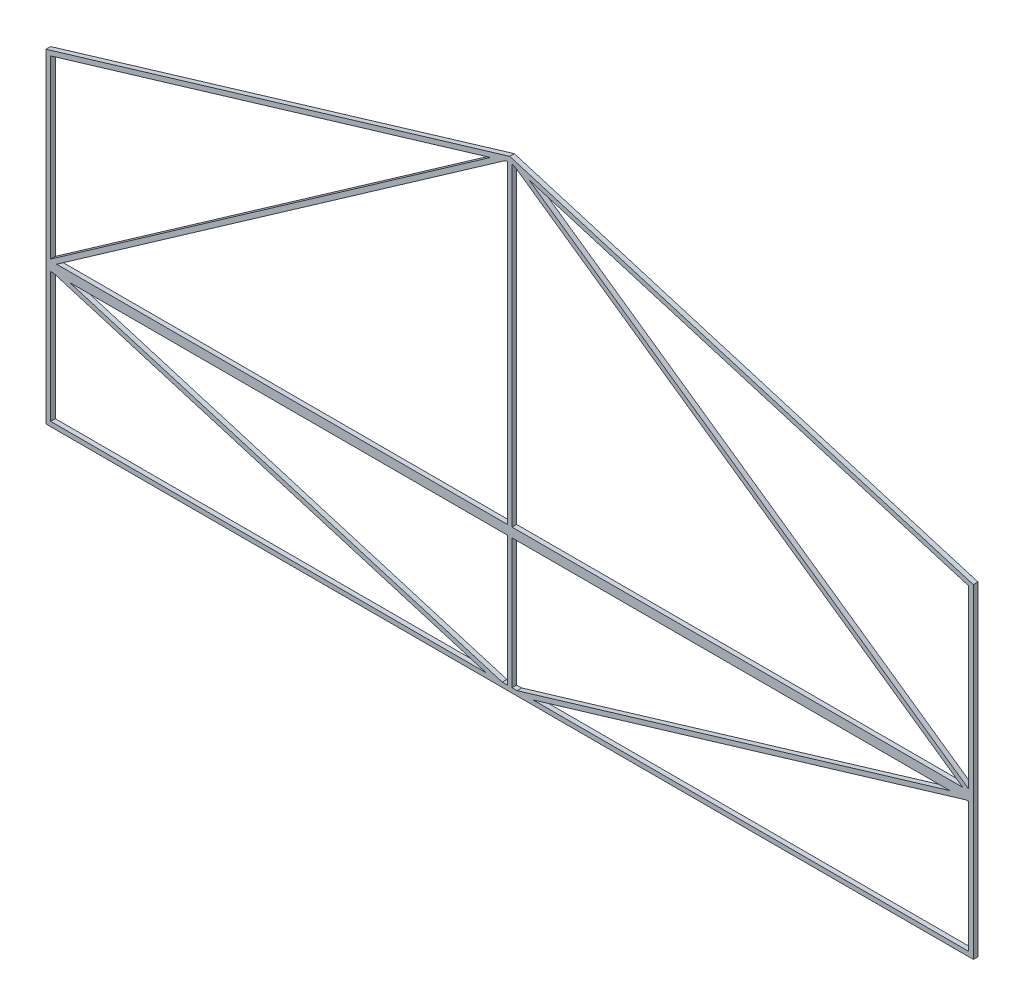
from build123d import *

# Parameters (mm, degrees)
EXTRUDE_1_DEPTH = 2


with BuildPart() as part:
    # Model → ﾎﾞｽ - 押し出し1 (new body)
    with BuildSketch(Plane.XY):
        Polygon((396.51989783, 60), (400, 60), (400, 61.22065558), (400, 140), (203.051638949, 199.084508315), (201, 199.7), (200, 200), (198.999999985, 199.699999996), (196.948361051, 199.084508315), (0, 140), (0, 61.22065558), (0, 60), (200, 60), align=None)
        Polygon((202.168514351, 197.261384393), (395.399063483, 62), (201, 62), (201, 197.611938698), align=None, mode=Mode.SUBTRACT)
        Polygon((2, 62.62065558), (2, 138.511938698), (191.728207796, 195.430401037), align=None, mode=Mode.SUBTRACT)
        Polygon((198.999999985, 197.611938694), (197.831485649, 197.261384393), (4.600936517, 62), (198.999999985, 62), align=None, mode=Mode.SUBTRACT)
        Polygon((398, 62.62065558), (398, 138.511938698), (208.271792204, 195.430401037), align=None, mode=Mode.SUBTRACT)
        Polygon((400, 0), (400, 58.955969334), (400, 60), (396.51989783, 60), (200, 60), (0, 60), (0, 58.955969334), (0, 0), align=None)
        Polygon((389.853231164, 58), (203.186564497, 2), (201, 2), (201, 58), align=None, mode=Mode.SUBTRACT)
        Polygon((210.146768888, 2), (396.813435555, 58), (398, 58), (398, 2), align=None, mode=Mode.SUBTRACT)
        Polygon((3.186564445, 58), (189.853231112, 2), (2, 2), (2, 58), align=None, mode=Mode.SUBTRACT)
        Polygon((196.813435503, 2), (198.999999985, 2), (198.999999985, 58), (10.146768836, 58), align=None, mode=Mode.SUBTRACT)
    extrude(amount=EXTRUDE_1_DEPTH)


solid = part.part
